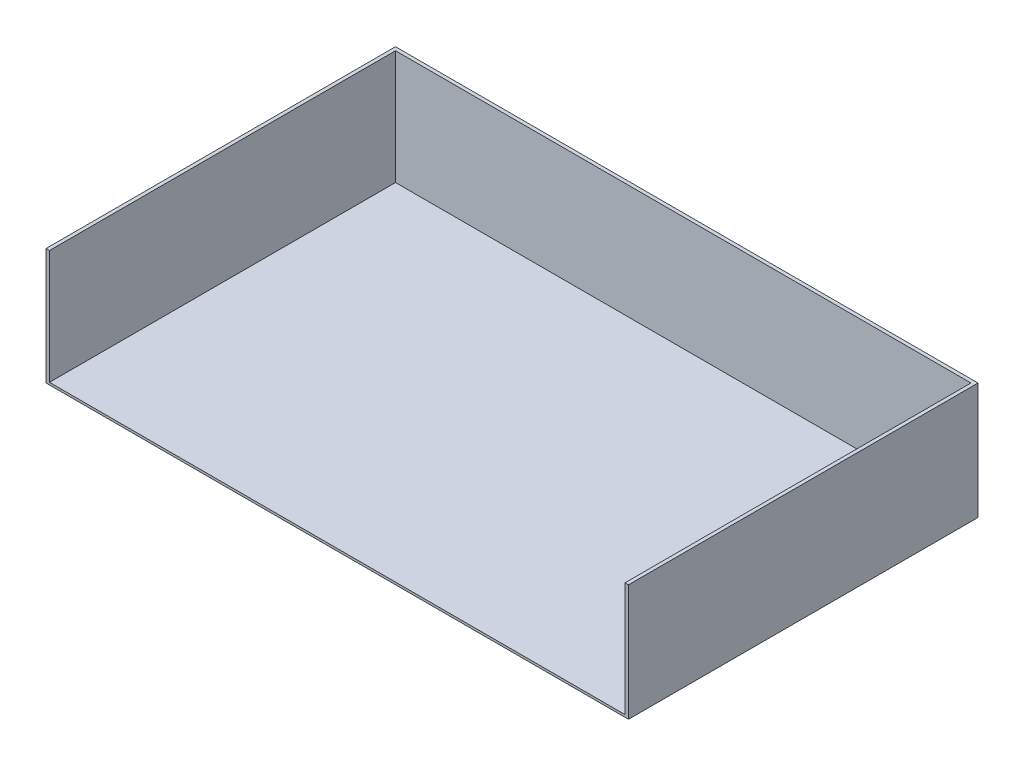
from build123d import *

# Parameters (mm, degrees)
SKETCH1_W           = 635
SKETCH1_H           = 127
BOSS_EXTRUDE1_DEPTH = 381
SKETCH2_W           = 627.38
SKETCH2_H           = 377.19
CUT_EXTRUDE1_DEPTH  = 124.46


with BuildPart() as part:
    # Sketch1 → Boss-Extrude1 (new body)
    with BuildSketch(Plane.XY):
        with Locations((317.5, 63.5)):
            Rectangle(SKETCH1_W, SKETCH1_H)
    extrude(amount=BOSS_EXTRUDE1_DEPTH)

    # Sketch2 → Cut-Extrude1 (cut)
    with BuildSketch(Plane(origin=(0, 127, 0), x_dir=(1, 0, 0), z_dir=(0, 1, 0))):
        with Locations((317.5, -192.405)):
            Rectangle(SKETCH2_W, SKETCH2_H)
    extrude(amount=-CUT_EXTRUDE1_DEPTH, mode=Mode.SUBTRACT)


solid = part.part
